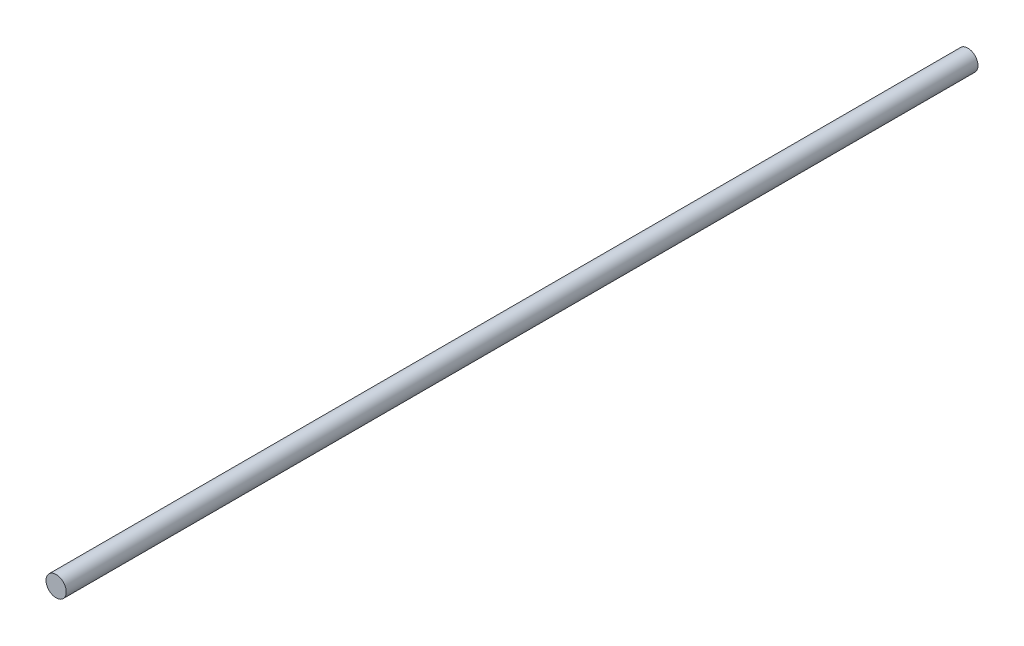
from build123d import *

# Parameters (mm, degrees)
SKETCH1_R           = 3
BOSS_EXTRUDE1_DEPTH = 270


with BuildPart() as part:
    # Sketch1 → Boss-Extrude1 (new body)
    with BuildSketch(Plane.XY):
        Circle(SKETCH1_R)
    extrude(amount=BOSS_EXTRUDE1_DEPTH)


solid = part.part
